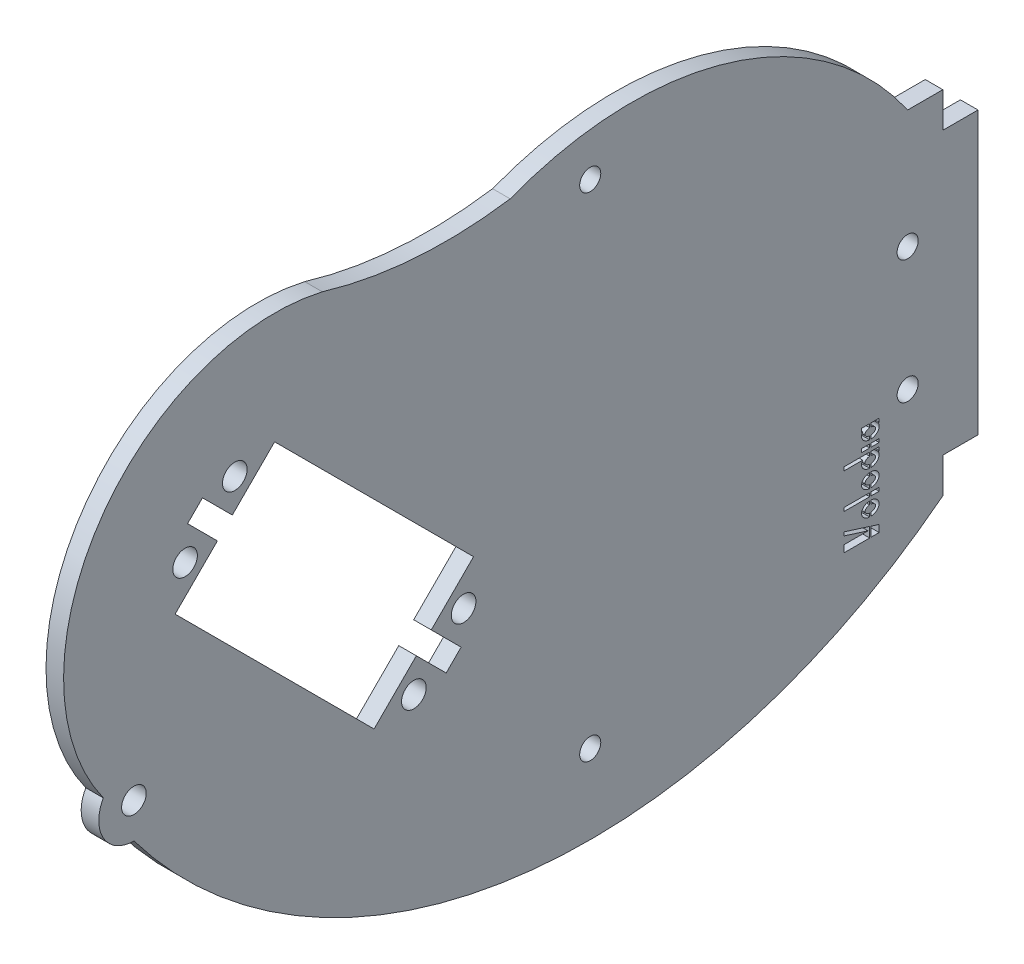
from build123d import *

# Parameters (mm, degrees)
CROQUIS1_R              = 1.75
CROQUIS1_R_2            = 1.5
CROQUIS1_W              = 3.65
CROQUIS1_H              = 0.5
CROQUIS1_W_2            = 1.15
SALIENTE_EXTRUIR1_DEPTH = 2.5


with BuildPart() as part:
    # Croquis1 → Saliente-Extruir1 (new body)
    with BuildSketch(Plane(origin=(0, 0, 0), x_dir=(0, 0, -1), z_dir=(1, 0, 0))):
        with BuildLine():
            Line((95, 10), (90, 10))
            ThreePointArc((90, 10), (64.751798433, 28.463425825), (33.494108419, 27.311648705))
            ThreePointArc((33.494108419, 27.311648705), (20.033827629, 26.787261985), (6.785305839, 29.222587577))
            ThreePointArc((6.785305839, 29.222587577), (-24.970289012, 16.62782808), (-24.346472536, -17.528527464))
            ThreePointArc((-24.346472536, -17.528527464), (-24.321884003, -22.514223272), (-20, -25))
            ThreePointArc((-20, -25), (34.355278896, -56.609528466), (95, -40))
            Line((95, -40), (95, -35))
            Line((95, -35), (100, -35))
            Line((100, -35), (100, 5))
            Line((100, 5), (95, 5))
            Line((95, 5), (95, 10))
        make_face()
        with Locations((-12.730077402, 5.654698909)):
            Circle(CROQUIS1_R, mode=Mode.SUBTRACT)
        with Locations((-5.658477353, 12.726298958)):
            Circle(CROQUIS1_R, mode=Mode.SUBTRACT)
        with Locations((26.870057685, -19.798989873)):
            Circle(CROQUIS1_R, mode=Mode.SUBTRACT)
        with Locations((19.797157185, -26.871890373)):
            Circle(CROQUIS1_R, mode=Mode.SUBTRACT)
        with Locations((-20, -20)):
            Circle(CROQUIS1_R, mode=Mode.SUBTRACT)
        with Locations((90, -6.821183735)):
            Circle(CROQUIS1_R_2, mode=Mode.SUBTRACT)
        with Locations((90, -24.395183951)):
            Circle(CROQUIS1_R_2, mode=Mode.SUBTRACT)
        with Locations((44.87119885, -46.048776814)):
            Circle(CROQUIS1_R_2, mode=Mode.SUBTRACT)
        with Locations((44.87119885, 24.012524519)):
            Circle(CROQUIS1_R_2, mode=Mode.SUBTRACT)
        Polygon((-14.142135624, 0), (14.142135624, -28.284271247), (20.150710576, -22.275696296), (24.393351263, -26.518336983), (26.516504294, -24.395183951), (22.273863607, -20.152543264), (28.284271247, -14.142135624), (0, 14.142135624), (-6.01040764, 8.131727984), (-10.253048327, 12.374368671), (-12.374368671, 10.253048327), (-8.131727984, 6.01040764), align=None, mode=Mode.SUBTRACT)
        Polygon((80.943094321, -40), (84.593094321, -40), (84.593094321, -38.572373471), (80.943094321, -37.416198041), (80.943094321, -37.916198041), (84.364614142, -39), (80.943094321, -39), align=None, mode=Mode.SUBTRACT)
        Polygon((85.943094321, -40), (85.943094321, -39), (84.793094321, -38.635725549), (84.793094321, -40), align=None, mode=Mode.SUBTRACT)
        with Locations((82.768094321, -34.666198041)):
            Rectangle(CROQUIS1_W, CROQUIS1_H, mode=Mode.SUBTRACT)
        with Locations((85.368094321, -34.666198041)):
            Rectangle(CROQUIS1_W_2, CROQUIS1_H, mode=Mode.SUBTRACT)
        with BuildLine():
            Line((80.943094321, -29.91623355), (83.610164163, -29.91623355))
            add(Edge.make_bspline(
                [(83.610164163, -29.91623355), (82.623079411, -31.28548871), (84.593094321, -31.412977868)],
                knots=[2.619761871, 2.619761871, 2.619761871, 4.633434758, 4.633434758, 4.633434758], degree=2, weights=[1, 0.534537056, 1]))
            Line((84.593094321, -31.412977868), (84.593094321, -30.911716069))
            add(Edge.make_bspline(
                [(84.593094321, -29.920643083), (83.943040701, -29.978586956), (83.943040701, -30.415828716), (83.943040701, -30.853070475), (84.593094321, -30.911716069)],
                knots=[1.705165867, 1.705165867, 1.705165867, 3.142240222, 3.142240222, 4.579314577, 4.579314577, 4.579314577], degree=2, weights=[1, 0.752769487, 1, 0.752769487, 1]))
            Line((84.593094321, -29.920643083), (84.593094321, -29.41623355))
            Line((84.593094321, -29.41623355), (80.943094321, -29.41623355))
            Line((80.943094321, -29.41623355), (80.943094321, -29.91623355))
        make_face(mode=Mode.SUBTRACT)
        with BuildLine():
            Line((85.943094321, -29.91623355), (85.943094321, -29.41623355))
            Line((85.943094321, -29.41623355), (84.793094321, -29.41623355))
            Line((84.793094321, -29.41623355), (84.793094321, -29.920751031))
            add(Edge.make_bspline(
                [(84.793094321, -30.911824017), (85.443147941, -30.853880144), (85.443147941, -30.416638385), (85.443147941, -29.979396625), (84.793094321, -29.920751031)],
                knots=[4.846758521, 4.846758521, 4.846758521, 6.283832876, 6.283832876, 7.720907231, 7.720907231, 7.720907231], degree=2, weights=[1, 0.752769487, 1, 0.752769487, 1]))
            Line((84.793094321, -30.911824017), (84.793094321, -31.413079686))
            add(Edge.make_bspline(
                [(84.793094321, -31.413079686), (86.765887036, -31.287419419), (85.775229026, -29.91623355)],
                knots=[4.793605815, 4.793605815, 4.793605815, 6.808551426, 6.808551426, 6.808551426], degree=2, weights=[1, 0.533999129, 1]))
            Line((85.775229026, -29.91623355), (85.943094321, -29.91623355))
        make_face(mode=Mode.SUBTRACT)
        with Locations((84.018094321, -28.66623355)):
            Rectangle(CROQUIS1_W_2, CROQUIS1_H, mode=Mode.SUBTRACT)
        with Locations((85.368094321, -28.66623355)):
            Rectangle(CROQUIS1_W_2, CROQUIS1_H, mode=Mode.SUBTRACT)
        with BuildLine():
            Line((83.443094321, -25.916233633), (84.593094321, -25.916233633))
            Line((84.593094321, -25.916233633), (84.593094321, -26.420682946))
            add(Edge.make_bspline(
                [(84.593094321, -26.420682946), (83.943040847, -26.478884039), (83.943040847, -26.916125604), (83.943040847, -27.353367169), (84.593094321, -27.411755514)],
                knots=[4.846283779, 4.846283779, 4.846283779, 6.283358108, 6.283358108, 7.720432437, 7.720432437, 7.720432437], degree=2, weights=[1, 0.752769496, 1, 0.752769496, 1]))
            Line((84.593094321, -27.411755514), (84.593094321, -27.913013902))
            add(Edge.make_bspline(
                [(83.610448256, -26.416233633), (82.622090752, -27.786175825), (84.593094321, -27.913013902)],
                knots=[5.760094352, 5.760094352, 5.760094352, 7.774221046, 7.774221046, 7.774221046], degree=2, weights=[1, 0.534345276, 1]))
            Line((83.610448256, -26.416233633), (83.443094321, -26.416233633))
            Line((83.443094321, -26.416233633), (83.443094321, -25.916233633))
        make_face(mode=Mode.SUBTRACT)
        with BuildLine():
            Line((85.943094321, -25.916233633), (85.943094321, -26.416233633))
            Line((85.943094321, -26.416233633), (85.775511878, -26.416233633))
            add(Edge.make_bspline(
                [(84.793094321, -27.913043151), (86.76489586, -27.786730453), (85.775511878, -26.416233633)],
                knots=[1.65120689, 1.65120689, 1.65120689, 3.665699196, 3.665699196, 3.665699196], degree=2, weights=[1, 0.534190747, 1]))
            Line((84.793094321, -27.913043151), (84.793094321, -27.41178432))
            add(Edge.make_bspline(
                [(84.793094321, -27.41178432), (85.443147794, -27.353583226), (85.443147794, -26.916341661), (85.443147794, -26.479100096), (84.793094321, -26.420711751)],
                knots=[1.704691126, 1.704691126, 1.704691126, 3.141765455, 3.141765455, 4.578839783, 4.578839783, 4.578839783], degree=2, weights=[1, 0.752769496, 1, 0.752769496, 1]))
            Line((84.793094321, -26.420711751), (84.793094321, -25.916233633))
            Line((84.793094321, -25.916233633), (85.943094321, -25.916233633))
        make_face(mode=Mode.SUBTRACT)
        with BuildLine():
            Line((84.593094321, -37.412992904), (84.593094321, -36.911734305))
            add(Edge.make_bspline(
                [(84.593094321, -35.920661776), (83.943040858, -35.978956494), (83.943040858, -36.416198041), (83.943040858, -36.853439587), (84.593094321, -36.911734305)],
                knots=[4.84611098, 4.84611098, 4.84611098, 6.283185307, 6.283185307, 7.720259634, 7.720259634, 7.720259634], degree=2, weights=[1, 0.752769496, 1, 0.752769496, 1]))
            Line((84.593094321, -35.920661776), (84.593094321, -35.419403177))
            add(Edge.make_bspline(
                [(84.593094321, -35.419403177), (83.443094321, -35.493239834), (83.443094321, -36.416198041), (83.443094321, -37.339156247), (84.593094321, -37.412992904)],
                knots=[4.79247456, 4.79247456, 4.79247456, 6.283185307, 6.283185307, 7.773896054, 7.773896054, 7.773896054], degree=2, weights=[1, 0.734846923, 1, 0.734846923, 1]))
        make_face(mode=Mode.SUBTRACT)
        with BuildLine():
            Line((84.793094321, -37.412992904), (84.793094321, -36.911734305))
            add(Edge.make_bspline(
                [(84.793094321, -36.911734305), (85.443147783, -36.853439587), (85.443147783, -36.416198041), (85.443147783, -35.978956494), (84.793094321, -35.920661776)],
                knots=[1.704518327, 1.704518327, 1.704518327, 3.141592654, 3.141592654, 4.57866698, 4.57866698, 4.57866698], degree=2, weights=[1, 0.752769496, 1, 0.752769496, 1]))
            Line((84.793094321, -35.920661776), (84.793094321, -35.419403177))
            add(Edge.make_bspline(
                [(84.793094321, -37.412992904), (85.943094321, -37.339156247), (85.943094321, -36.416198041), (85.943094321, -35.493239834), (84.793094321, -35.419403177)],
                knots=[1.650881907, 1.650881907, 1.650881907, 3.141592654, 3.141592654, 4.6323034, 4.6323034, 4.6323034], degree=2, weights=[1, 0.734846923, 1, 0.734846923, 1]))
        make_face(mode=Mode.SUBTRACT)
        with BuildLine():
            Line((84.593094321, -32.420514096), (84.593094321, -31.919284925))
            add(Edge.make_bspline(
                [(84.593094321, -31.919284925), (83.443089734, -31.991719576), (83.443089734, -32.914679961), (83.443089734, -33.837640345), (84.593094321, -33.912878813)],
                knots=[4.7951832, 4.7951832, 4.7951832, 6.285894241, 6.285894241, 7.776605282, 7.776605282, 7.776605282], degree=2, weights=[1, 0.734846823, 1, 0.734846823, 1]))
            Line((84.593094321, -33.912878813), (84.593094321, -33.411589135))
            add(Edge.make_bspline(
                [(84.593094321, -32.420514096), (83.943039608, -32.477819763), (83.943039608, -32.915062503), (83.943039608, -33.352305243), (84.593094321, -33.411589135)],
                knots=[4.847936306, 4.847936306, 4.847936306, 6.285010857, 6.285010857, 7.722085408, 7.722085408, 7.722085408], degree=2, weights=[1, 0.752769423, 1, 0.752769423, 1]))
        make_face(mode=Mode.SUBTRACT)
        with BuildLine():
            Line((84.793094321, -32.420818413), (84.793094321, -31.919528734))
            add(Edge.make_bspline(
                [(84.793094321, -33.913122623), (85.943098907, -33.840687971), (85.943098907, -32.917727587), (85.943098907, -31.994767202), (84.793094321, -31.919528734)],
                knots=[1.653590546, 1.653590546, 1.653590546, 3.144301587, 3.144301587, 4.635012628, 4.635012628, 4.635012628], degree=2, weights=[1, 0.734846823, 1, 0.734846823, 1]))
            Line((84.793094321, -33.913122623), (84.793094321, -33.411893451))
            add(Edge.make_bspline(
                [(84.793094321, -33.411893451), (85.443149033, -33.354587784), (85.443149033, -32.917345044), (85.443149033, -32.480102304), (84.793094321, -32.420818413)],
                knots=[1.706343653, 1.706343653, 1.706343653, 3.143418204, 3.143418204, 4.580492754, 4.580492754, 4.580492754], degree=2, weights=[1, 0.752769423, 1, 0.752769423, 1]))
        make_face(mode=Mode.SUBTRACT)
    extrude(amount=SALIENTE_EXTRUIR1_DEPTH)


solid = part.part
